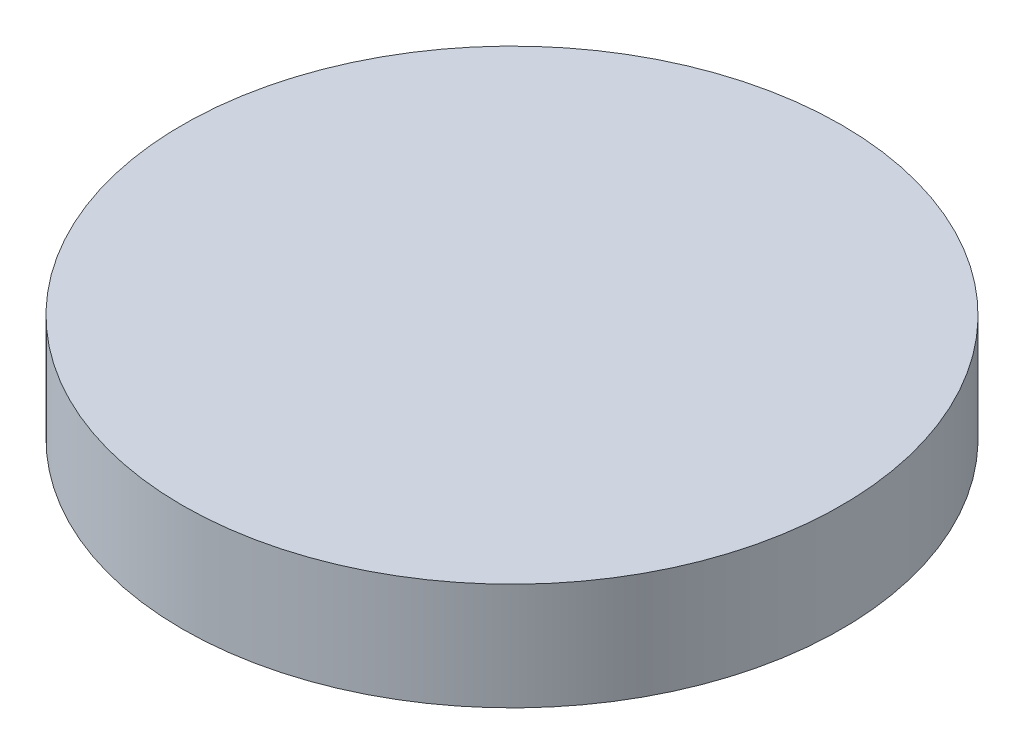
from build123d import *

# Parameters (mm, degrees)
SKETCH1_R           = 40
BOSS_EXTRUDE1_DEPTH = 13


with BuildPart() as part:
    # Sketch1 → Boss-Extrude1 (new body)
    with BuildSketch(Plane(origin=(0, 0, 0), x_dir=(1, 0, 0), z_dir=(0, 1, 0))):
        Circle(SKETCH1_R)
    extrude(amount=BOSS_EXTRUDE1_DEPTH)


solid = part.part
